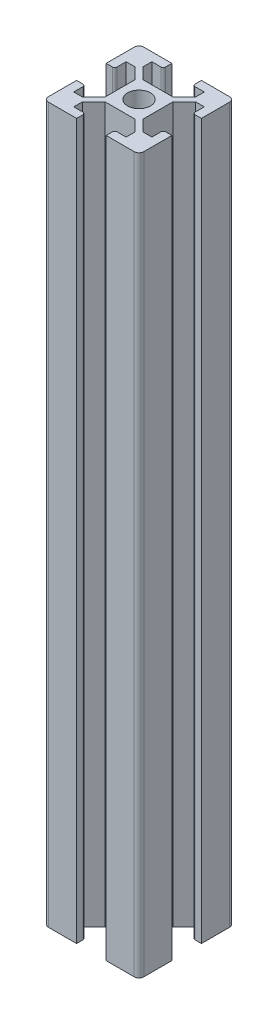
from build123d import *

# Parameters (mm, degrees)
SKETCH1_R           = 2.4
BOSS_EXTRUDE1_DEPTH = 150


with BuildPart() as part:
    # Sketch1 → Boss-Extrude1 (new body)
    with BuildSketch(Plane(origin=(0, 0, 0), x_dir=(1, 0, 0), z_dir=(0, 1, 0))):
        with BuildLine():
            ThreePointArc((-10, -9), (-9.707106781, -9.707106781), (-9, -10))
            Line((-9, -10), (-3.1, -10))
            Line((-3.1, -10), (-3.1, -8.7))
            ThreePointArc((-3.1, -8.7), (-3.246446609, -8.346446609), (-3.6, -8.2))
            Line((-3.6, -8.2), (-5.5, -8.2))
            Line((-5.5, -8.2), (-5.5, -6.376528763))
            Line((-5.5, -6.376528763), (-3.123471237, -4))
            Line((-3.123471237, -4), (0, -4))
            Line((0, -4), (3.123471237, -4))
            Line((3.123471237, -4), (5.5, -6.376528763))
            Line((5.5, -6.376528763), (5.5, -8.2))
            Line((5.5, -8.2), (3.6, -8.2))
            ThreePointArc((3.6, -8.2), (3.246446609, -8.346446609), (3.1, -8.7))
            Line((3.1, -8.7), (3.1, -10))
            Line((3.1, -10), (9, -10))
            ThreePointArc((9, -10), (9.707106781, -9.707106781), (10, -9))
            Line((10, -9), (10, -3.1))
            Line((10, -3.1), (8.7, -3.1))
            ThreePointArc((8.7, -3.1), (8.346446609, -3.246446609), (8.2, -3.6))
            Line((8.2, -3.6), (8.2, -5.5))
            Line((8.2, -5.5), (6.376528763, -5.5))
            Line((6.376528763, -5.5), (4, -3.123471237))
            Line((4, -3.123471237), (4, 0))
            Line((4, 0), (4, 3.123471237))
            Line((4, 3.123471237), (6.376528763, 5.5))
            Line((6.376528763, 5.5), (8.2, 5.5))
            Line((8.2, 5.5), (8.2, 3.6))
            ThreePointArc((8.2, 3.6), (8.346446609, 3.246446609), (8.7, 3.1))
            Line((8.7, 3.1), (10, 3.1))
            Line((10, 3.1), (10, 9))
            ThreePointArc((10, 9), (9.707106781, 9.707106781), (9, 10))
            Line((9, 10), (3.1, 10))
            Line((3.1, 10), (3.1, 8.7))
            ThreePointArc((3.1, 8.7), (3.246446609, 8.346446609), (3.6, 8.2))
            Line((3.6, 8.2), (5.5, 8.2))
            Line((5.5, 8.2), (5.5, 6.376528763))
            Line((5.5, 6.376528763), (3.123471237, 4))
            Line((3.123471237, 4), (0, 4))
            Line((0, 4), (-3.123471237, 4))
            Line((-3.123471237, 4), (-5.5, 6.376528763))
            Line((-5.5, 6.376528763), (-5.5, 8.2))
            Line((-5.5, 8.2), (-3.6, 8.2))
            ThreePointArc((-3.6, 8.2), (-3.246446609, 8.346446609), (-3.1, 8.7))
            Line((-3.1, 8.7), (-3.1, 10))
            Line((-3.1, 10), (-9, 10))
            ThreePointArc((-9, 10), (-9.707106781, 9.707106781), (-10, 9))
            Line((-10, 9), (-10, 3.1))
            Line((-10, 3.1), (-8.7, 3.1))
            ThreePointArc((-8.7, 3.1), (-8.346446609, 3.246446609), (-8.2, 3.6))
            Line((-8.2, 3.6), (-8.2, 5.5))
            Line((-8.2, 5.5), (-6.376528763, 5.5))
            Line((-6.376528763, 5.5), (-4, 3.123471237))
            Line((-4, 3.123471237), (-4, 0))
            Line((-4, 0), (-4, -3.123471237))
            Line((-4, -3.123471237), (-6.376528763, -5.5))
            Line((-6.376528763, -5.5), (-8.2, -5.5))
            Line((-8.2, -5.5), (-8.2, -3.6))
            ThreePointArc((-8.2, -3.6), (-8.346446609, -3.246446609), (-8.7, -3.1))
            Line((-8.7, -3.1), (-10, -3.1))
            Line((-10, -3.1), (-10, -9))
        make_face()
        Circle(SKETCH1_R, mode=Mode.SUBTRACT)
    extrude(amount=BOSS_EXTRUDE1_DEPTH)


solid = part.part
